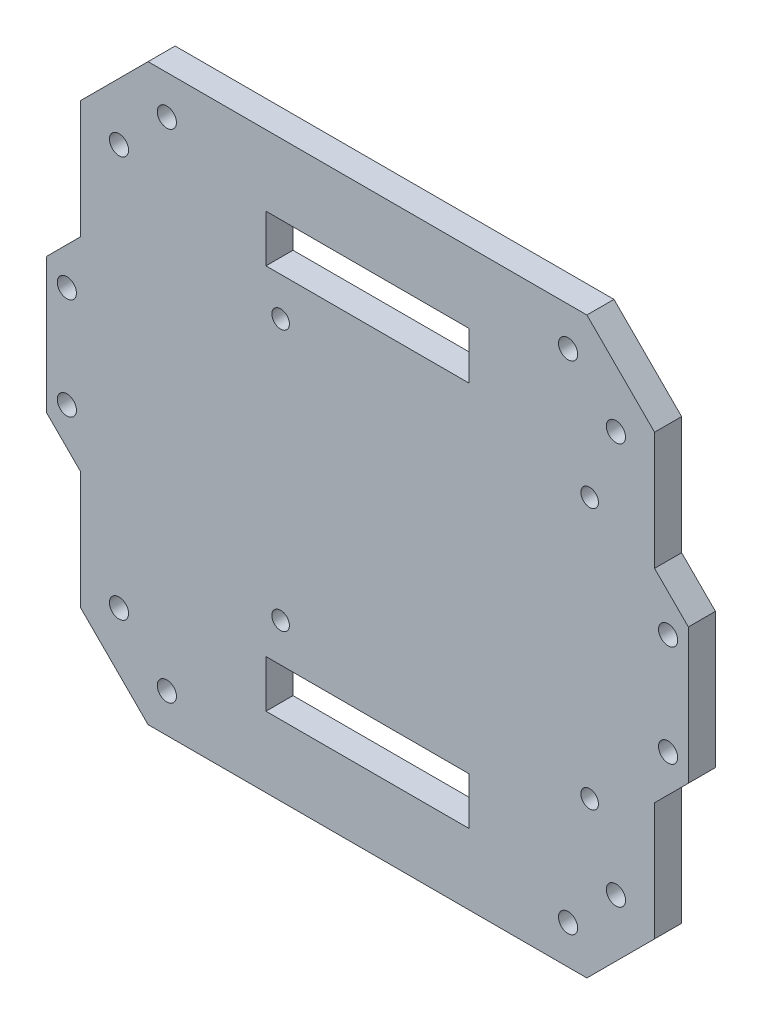
from build123d import *

# Parameters (mm, degrees)
SKETCH1_R           = 1.800000083
SKETCH1_R_2         = 1.650000002
SKETCH1_W           = 8.89
SKETCH1_H           = 38.1
BOSS_EXTRUDE1_DEPTH = 2.54


with BuildPart() as part:
    # Sketch1 → Boss-Extrude1 (new body, symmetric)
    with BuildSketch(Plane(origin=(0, 0, 0), x_dir=(0, 1, 0), z_dir=(0, 0, 1))):
        Polygon((-41.181536726, 53.881536726), (-19.05, 53.881536726), (-12.7, 60.231536726), (12.7, 60.231536726), (19.05, 53.881536726), (41.181536726, 53.881536726), (53.881536726, 41.181536726), (53.881536726, -41.181536726), (41.181536726, -53.881536726), (19.05, -53.881536726), (12.7, -60.231536726), (-12.7, -60.231536726), (-19.05, -53.881536726), (-41.181536726, -53.881536726), (-53.881536726, -41.181536726), (-53.881536726, 41.181536726), align=None)
        with Locations((-46.633511114, -37.653254993)):
            Circle(SKETCH1_R, mode=Mode.SUBTRACT)
        with Locations((-37.653254993, -46.633511114)):
            Circle(SKETCH1_R, mode=Mode.SUBTRACT)
        with Locations((46.633511114, -37.653254993)):
            Circle(SKETCH1_R, mode=Mode.SUBTRACT)
        with Locations((37.653254993, -46.633511114)):
            Circle(SKETCH1_R, mode=Mode.SUBTRACT)
        with Locations((-46.633511114, 37.653254993)):
            Circle(SKETCH1_R, mode=Mode.SUBTRACT)
        with Locations((-37.653254993, 46.633511114)):
            Circle(SKETCH1_R, mode=Mode.SUBTRACT)
        with Locations((37.653254993, 46.633511114)):
            Circle(SKETCH1_R, mode=Mode.SUBTRACT)
        with Locations((46.633511114, 37.653254993)):
            Circle(SKETCH1_R, mode=Mode.SUBTRACT)
        with Locations((-24.5, -41.7)):
            Circle(SKETCH1_R_2, mode=Mode.SUBTRACT)
        with Locations((24.5, -41.7)):
            Circle(SKETCH1_R_2, mode=Mode.SUBTRACT)
        with Locations((24.5, 16.3)):
            Circle(SKETCH1_R_2, mode=Mode.SUBTRACT)
        with Locations((-24.5, 16.3)):
            Circle(SKETCH1_R_2, mode=Mode.SUBTRACT)
        with Locations((-9.525, -56.421536726)):
            Circle(SKETCH1_R, mode=Mode.SUBTRACT)
        with Locations((9.525, -56.421536726)):
            Circle(SKETCH1_R, mode=Mode.SUBTRACT)
        with Locations((9.525, 56.421536726)):
            Circle(SKETCH1_R, mode=Mode.SUBTRACT)
        with Locations((-9.525, 56.421536726)):
            Circle(SKETCH1_R, mode=Mode.SUBTRACT)
        with Locations((36.195, 0)):
            Rectangle(SKETCH1_W, SKETCH1_H, mode=Mode.SUBTRACT)
        with Locations((-36.195, 0)):
            Rectangle(SKETCH1_W, SKETCH1_H, mode=Mode.SUBTRACT)
    extrude(amount=BOSS_EXTRUDE1_DEPTH, both=True)


solid = part.part
